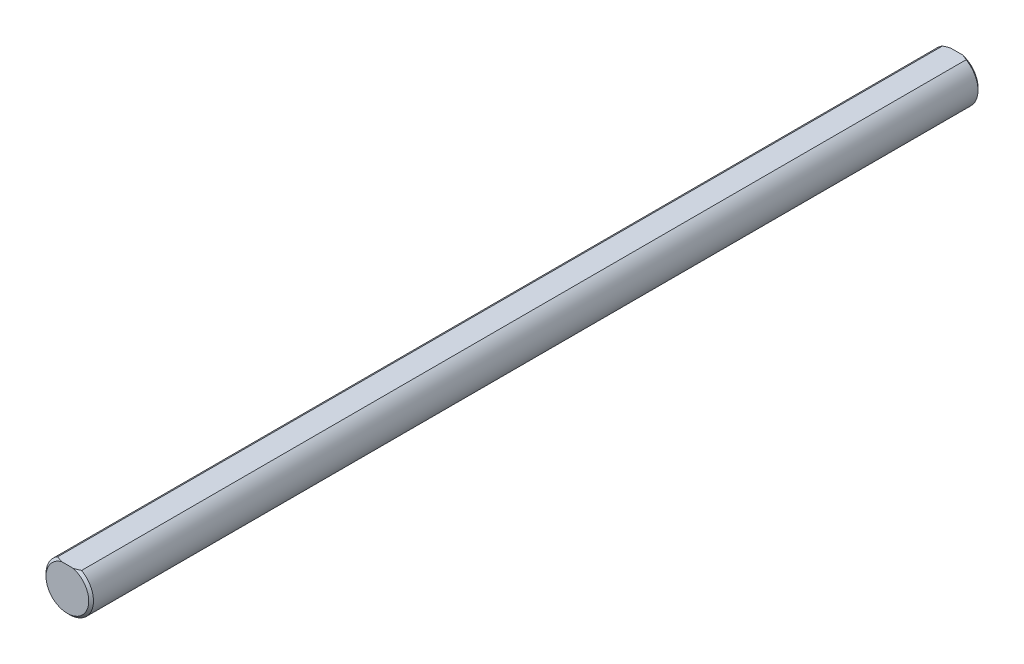
from build123d import *

# Parameters (mm, degrees)
SKETCH3_R                = 3.175
BOSS_EXTRUDE2_DEPTH      = 59.425
BOSS_EXTRUDE2_DEPTH_BACK = 59.425
CUT_EXTRUDE5_DEPTH       = 60.425
CUT_EXTRUDE5_DEPTH_BACK  = 60.425
CHAMFER1_SIZE            = 0.3175


with BuildPart() as part:
    # Sketch3 → Boss-Extrude2 (new body, two sides)
    with BuildSketch(Plane.XY) as boss_extrude2_sk:
        Circle(SKETCH3_R)
    extrude(amount=BOSS_EXTRUDE2_DEPTH)
    extrude(boss_extrude2_sk.sketch, amount=-BOSS_EXTRUDE2_DEPTH_BACK)

    # Sketch10 → Cut-Extrude5 (cut, two sides)
    with BuildSketch(Plane.XY) as cut_extrude5_sk:
        with BuildLine():
            Line((-1.5875, 2.749630657), (1.5875, 2.749630657))
            ThreePointArc((1.5875, 2.749630657), (0, 3.175), (-1.5875, 2.749630657))
        make_face()
    extrude(amount=CUT_EXTRUDE5_DEPTH, mode=Mode.SUBTRACT)
    extrude(cut_extrude5_sk.sketch, amount=-CUT_EXTRUDE5_DEPTH_BACK, mode=Mode.SUBTRACT)

    # Chamfer1
    chamfer1_edges = [part.edges().sort_by_distance(p)[0] for p in [
        (0, -3.175, -59.425),
        (0, -3.175, 59.425),
    ]]
    chamfer(chamfer1_edges, length=CHAMFER1_SIZE)


solid = part.part
